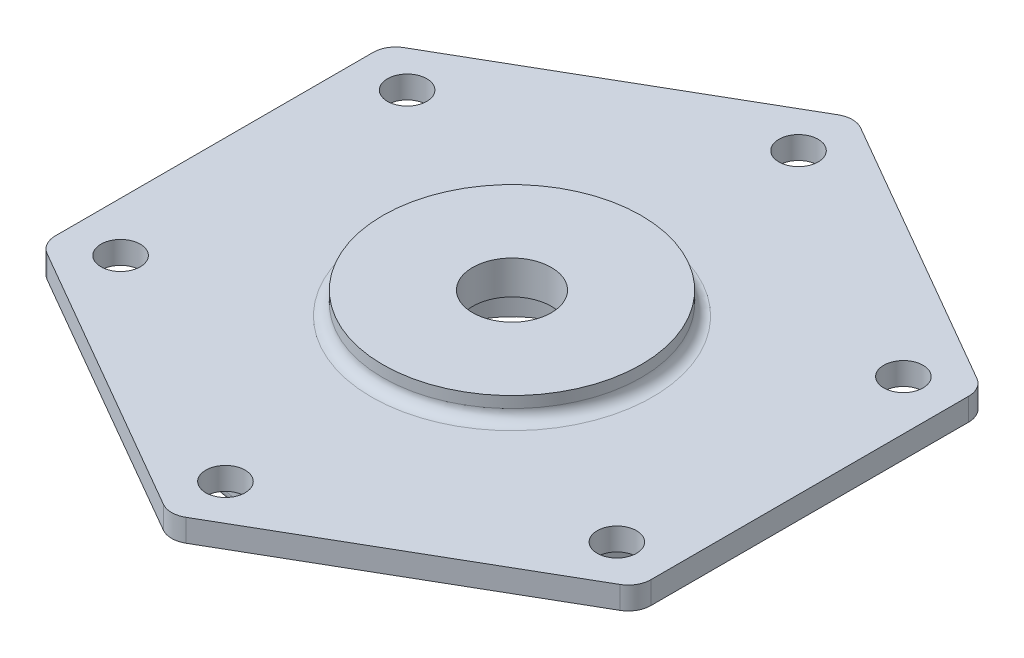
from build123d import *

# Parameters (mm, degrees)
BOSS_EXTRUDE1_DEPTH = 4
SKETCH2_R           = 23
BOSS_EXTRUDE2_DEPTH = 4
SKETCH3_R           = 45
BOSS_EXTRUDE3_DEPTH = 6
SKETCH4_R           = 40
SKETCH4_R_2         = 19
CUT_EXTRUDE1_DEPTH  = 6
SKETCH5_R           = 14
CUT_EXTRUDE2_DEPTH  = 8
SKETCH6_R           = 7
CUT_EXTRUDE3_DEPTH  = 7
FILLET1_R           = 2
SKETCH7_R           = 3.5
CUT_EXTRUDE4_DEPTH  = 11


with BuildPart() as part:
    # Sketch1 → Boss-Extrude1 (new body)
    with BuildSketch(Plane(origin=(0, 0, 0), x_dir=(1, 0, 0), z_dir=(0, 1, 0))):
        with BuildLine():
            Line((-2, 60.044427996), (-51, 31.754264805))
            ThreePointArc((-51, 31.754264805), (-52.464101615, 30.29016319), (-53, 28.29016319))
            Line((-53, 28.29016319), (-53, -28.29016319))
            ThreePointArc((-53, -28.29016319), (-52.464101615, -30.29016319), (-51, -31.754264805))
            Line((-51, -31.754264805), (-2, -60.044427996))
            ThreePointArc((-2, -60.044427996), (0, -60.580326381), (2, -60.044427996))
            Line((2, -60.044427996), (51, -31.754264805))
            ThreePointArc((51, -31.754264805), (52.464101615, -30.29016319), (53, -28.29016319))
            Line((53, -28.29016319), (53, 28.29016319))
            ThreePointArc((53, 28.29016319), (52.464101615, 30.29016319), (51, 31.754264805))
            Line((51, 31.754264805), (2, 60.044427996))
            ThreePointArc((2, 60.044427996), (0, 60.580326381), (-2, 60.044427996))
        make_face()
    extrude(amount=BOSS_EXTRUDE1_DEPTH)

    # Sketch2 → Boss-Extrude2 (add)
    with BuildSketch(Plane(origin=(0, 4, 0), x_dir=(1, 0, 0), z_dir=(0, 1, 0))):
        Circle(SKETCH2_R)
    extrude(amount=BOSS_EXTRUDE2_DEPTH)

    # Sketch3 → Boss-Extrude3 (add)
    with BuildSketch(Plane.XZ):
        Circle(SKETCH3_R)
    extrude(amount=BOSS_EXTRUDE3_DEPTH)

    # Sketch4 → Cut-Extrude1 (cut)
    with BuildSketch(Plane.XZ.offset(6)):
        Circle(SKETCH4_R)
        Circle(SKETCH4_R_2, mode=Mode.SUBTRACT)
    extrude(amount=-CUT_EXTRUDE1_DEPTH, mode=Mode.SUBTRACT)

    # Sketch5 → Cut-Extrude2 (cut)
    with BuildSketch(Plane.XZ.offset(6)):
        Circle(SKETCH5_R)
    extrude(amount=-CUT_EXTRUDE2_DEPTH, mode=Mode.SUBTRACT)

    # Sketch6 → Cut-Extrude3 (cut, through all)
    with BuildSketch(Plane.XZ.offset(-2)):
        Circle(SKETCH6_R)
    extrude(amount=-CUT_EXTRUDE3_DEPTH, mode=Mode.SUBTRACT)

    # Fillet1
    fillet1_edges = [part.edges().sort_by_distance(p)[0] for p in [
        (-23, 4, 0),
        (-45, -6, 0),
        (-19, -6, 0),
    ]]
    fillet(fillet1_edges, radius=FILLET1_R)

    # Sketch7 → Cut-Extrude4 (cut, through all)
    with BuildSketch(Plane(origin=(0, 4, 0), x_dir=(1, 0, 0), z_dir=(0, 1, 0))):
        with Locations((0, 51)):
            Circle(SKETCH7_R)
        with Locations((44.167295593, 25.5)):
            Circle(SKETCH7_R)
        with Locations((44.167295593, -25.5)):
            Circle(SKETCH7_R)
        with Locations((0, -51)):
            Circle(SKETCH7_R)
        with Locations((-44.167295593, -25.5)):
            Circle(SKETCH7_R)
        with Locations((-44.167295593, 25.5)):
            Circle(SKETCH7_R)
    extrude(amount=-CUT_EXTRUDE4_DEPTH, mode=Mode.SUBTRACT)


solid = part.part
